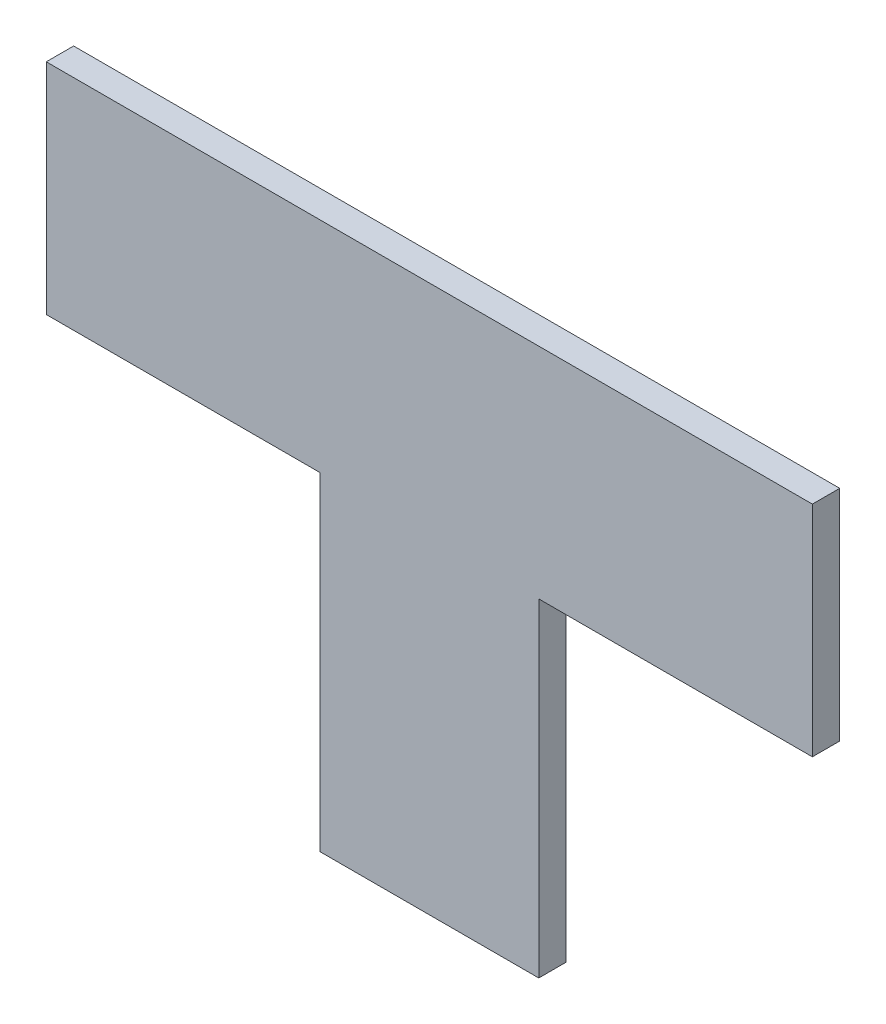
from build123d import *

# Parameters (mm, degrees)
BOSS_EXTRUDE1_DEPTH = 3.175


with BuildPart() as part:
    # Sketch1 → Boss-Extrude1 (new body)
    with BuildSketch(Plane.XY):
        Polygon((0, 0), (0, 38.1), (-31.75, 38.1), (-31.75, 63.5), (57.15, 63.5), (57.15, 38.1), (25.4, 38.1), (25.4, 0), align=None)
    extrude(amount=BOSS_EXTRUDE1_DEPTH)


solid = part.part
